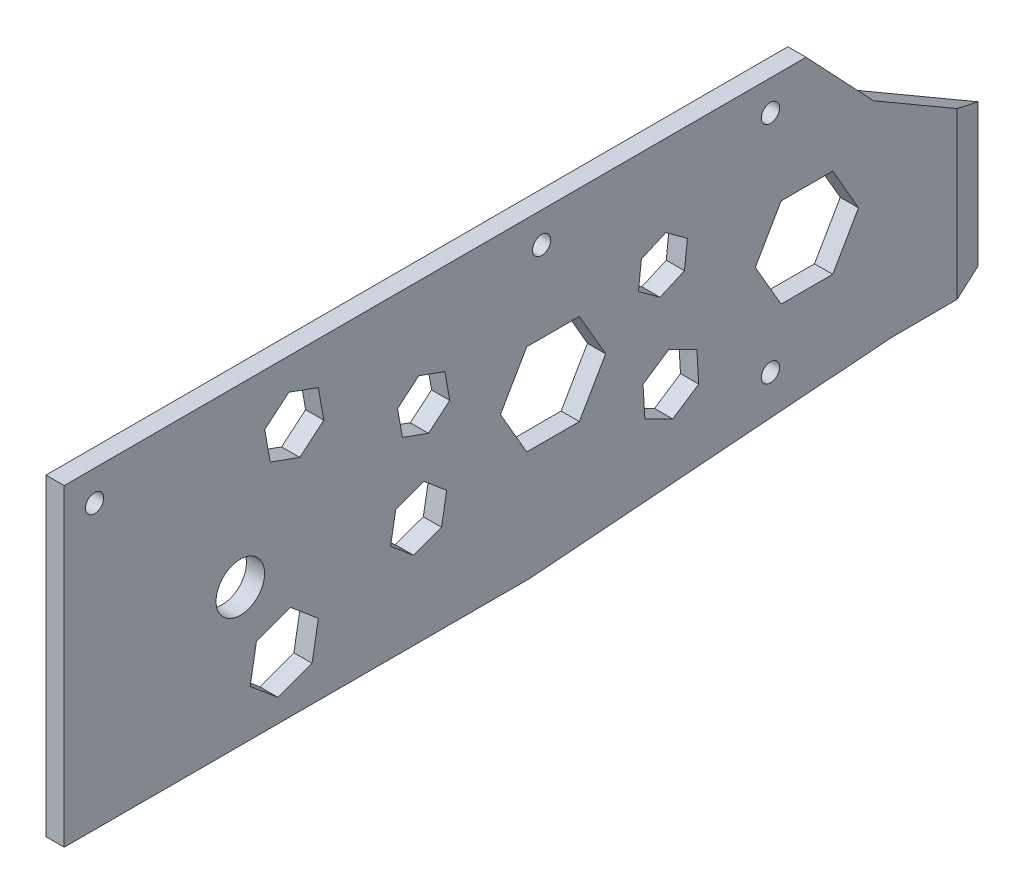
from build123d import *

# Parameters (mm, degrees)
CROQUIS1_W              = 161
CROQUIS1_H              = 51.5812
SALIENTE_EXTRUIR1_DEPTH = 3
CORTAR_EXTRUIR1_REACH   = 5
CROQUIS2_R              = 1.5
CROQUIS2_R_2            = 4
CORTAR_EXTRUIR2_REACH   = 5
CROQUIS3_R              = 1.5
CORTAR_EXTRUIR3_REACH   = 53.581
CORTAR_EXTRUIR4_REACH   = 5
CORTAR_EXTRUIR5_REACH   = 5
CORTAR_EXTRUIR6_REACH   = 5
CORTAR_EXTRUIR7_REACH   = 5
CORTAR_EXTRUIR8_REACH   = 5
CROQUIS9_R              = 1.5


with BuildPart() as part:
    # Croquis1 → Saliente-Extruir1 (new body)
    with BuildSketch(Plane(origin=(0, 0, 0), x_dir=(0, 0, -1), z_dir=(1, 0, 0))):
        Rectangle(CROQUIS1_W, CROQUIS1_H)
    extrude(amount=SALIENTE_EXTRUIR1_DEPTH)

    # Croquis2 → Cortar-Extruir1 (cut, up to next)
    with BuildSketch(Plane(origin=(3, 0, 0), x_dir=(0, 0, -1), z_dir=(1, 0, 0)), mode=Mode.PRIVATE) as cortar_extruir1_sk1:
        with Locations((-75.5, 20.7906)):
            Circle(CROQUIS2_R)
    cortar_extruir1_tool1 = extrude(cortar_extruir1_sk1.sketch, amount=-CORTAR_EXTRUIR1_REACH, mode=Mode.PRIVATE) & part.part
    add(cortar_extruir1_tool1.solids().sort_by_distance((3, 20.7906, 75.5))[0], mode=Mode.SUBTRACT)
    # Croquis2 → Cortar-Extruir1 (cut, up to next)
    with BuildSketch(Plane(origin=(3, 0, 0), x_dir=(0, 0, -1), z_dir=(1, 0, 0)), mode=Mode.PRIVATE) as cortar_extruir1_sk2:
        with Locations((-1.88, 20.7906)):
            Circle(CROQUIS2_R)
    cortar_extruir1_tool2 = extrude(cortar_extruir1_sk2.sketch, amount=-CORTAR_EXTRUIR1_REACH, mode=Mode.PRIVATE) & part.part
    add(cortar_extruir1_tool2.solids().sort_by_distance((3, 20.7906, 1.88))[0], mode=Mode.SUBTRACT)
    # Croquis2 → Cortar-Extruir1 (cut, up to next)
    with BuildSketch(Plane(origin=(3, 0, 0), x_dir=(0, 0, -1), z_dir=(1, 0, 0)), mode=Mode.PRIVATE) as cortar_extruir1_sk3:
        with Locations((-51.5, -3.2094)):
            Circle(CROQUIS2_R_2)
    cortar_extruir1_tool3 = extrude(cortar_extruir1_sk3.sketch, amount=-CORTAR_EXTRUIR1_REACH, mode=Mode.PRIVATE) & part.part
    add(cortar_extruir1_tool3.solids().sort_by_distance((3, -3.2094, 51.5))[0], mode=Mode.SUBTRACT)

    # Croquis3 → Cortar-Extruir2 (cut, up to next)
    with BuildSketch(Plane.ZY, mode=Mode.PRIVATE) as cortar_extruir2_sk1:
        with Locations((-35.801477372, -16.2094)):
            Circle(CROQUIS3_R)
    cortar_extruir2_tool1 = extrude(cortar_extruir2_sk1.sketch, amount=-CORTAR_EXTRUIR2_REACH, mode=Mode.PRIVATE) & part.part
    add(cortar_extruir2_tool1.solids().sort_by_distance((0, -16.2094, -35.801477))[0], mode=Mode.SUBTRACT)

    # Croquis4 → Cortar-Extruir3 (cut, up to next)
    with BuildSketch(Plane(origin=(0, 25.7906, 0), x_dir=(1, 0, 0), z_dir=(0, 1, 0)), mode=Mode.PRIVATE) as cortar_extruir3_sk1:
        Polygon((3, 80.5), (0, 80.5), (0, 72.980420108), (3, 66.546899347), align=None)
    cortar_extruir3_tool1 = extrude(cortar_extruir3_sk1.sketch, amount=-CORTAR_EXTRUIR3_REACH, mode=Mode.PRIVATE) & part.part
    add(cortar_extruir3_tool1.solids().sort_by_distance((1.649807, 25.7906, -74.971199))[0], mode=Mode.SUBTRACT)

    # Croquis5 → Cortar-Extruir4 (cut, up to next)
    with BuildSketch(Plane.ZY, mode=Mode.PRIVATE) as cortar_extruir4_sk1:
        Polygon((-72.980420108, -25.7906), (-72.980420108, -21.149469815), (-55.595458212, -21.2094), (3.759789946, -25.7906), align=None)
    cortar_extruir4_tool1 = extrude(cortar_extruir4_sk1.sketch, amount=-CORTAR_EXTRUIR4_REACH, mode=Mode.PRIVATE) & part.part
    add(cortar_extruir4_tool1.solids().sort_by_distance((0, -23.974753, -46.380283))[0], mode=Mode.SUBTRACT)

    # Croquis6 → Cortar-Extruir5 (cut, up to next)
    with BuildSketch(Plane.ZY, mode=Mode.PRIVATE) as cortar_extruir5_sk1:
        Polygon((-72.980420108, 25.7906), (-72.980420108, 2.2906), (-52.770420108, 14.0406), (-52.770420108, 25.7906), align=None)
    cortar_extruir5_tool1 = extrude(cortar_extruir5_sk1.sketch, amount=-CORTAR_EXTRUIR5_REACH, mode=Mode.PRIVATE) & part.part
    add(cortar_extruir5_tool1.solids().sort_by_distance((0, 16.651711, -63.998198))[0], mode=Mode.SUBTRACT)

    # Croquis7 → Cortar-Extruir6 (cut, up to next)
    with BuildSketch(Plane.ZY, mode=Mode.PRIVATE) as cortar_extruir6_sk1:
        Polygon((-52.770420108, 25.7906), (-41.670420108, 25.7906), (-52.770420108, 14.0406), align=None)
    cortar_extruir6_tool1 = extrude(cortar_extruir6_sk1.sketch, amount=-CORTAR_EXTRUIR6_REACH, mode=Mode.PRIVATE) & part.part
    add(cortar_extruir6_tool1.solids().sort_by_distance((0, 21.873933, -49.07042))[0], mode=Mode.SUBTRACT)

    # Croquis8 → Cortar-Extruir7 (cut, up to next)
    with BuildSketch(Plane.ZY, mode=Mode.PRIVATE) as cortar_extruir7_sk1:
        Polygon((8.660254038, 0), (4.330127019, 7.5), (-4.330127019, 7.5), (-8.660254038, 0), (-4.330127019, -7.5), (4.330127019, -7.5), align=None)
    cortar_extruir7_tool1 = extrude(cortar_extruir7_sk1.sketch, amount=-CORTAR_EXTRUIR7_REACH, mode=Mode.PRIVATE) & part.part
    add(cortar_extruir7_tool1.solids().sort_by_distance((0, 0, 0))[0], mode=Mode.SUBTRACT)
    # Croquis8 → Cortar-Extruir7 (cut, up to next)
    with BuildSketch(Plane.ZY, mode=Mode.PRIVATE) as cortar_extruir7_sk2:
        Polygon((25.604154883, 9.319150251), (22.099721379, 12.259719112), (17.800897292, 10.695075102), (17.006506709, 6.189862231), (20.510940213, 3.24929337), (24.8097643, 4.81393738), align=None)
    cortar_extruir7_tool2 = extrude(cortar_extruir7_sk2.sketch, amount=-CORTAR_EXTRUIR7_REACH, mode=Mode.PRIVATE) & part.part
    add(cortar_extruir7_tool2.solids().sort_by_distance((0, 7.754506, 21.305331))[0], mode=Mode.SUBTRACT)
    # Croquis8 → Cortar-Extruir7 (cut, up to next)
    with BuildSketch(Plane.ZY, mode=Mode.PRIVATE) as cortar_extruir7_sk3:
        Polygon((-23.988727728, -11.985830273), (-19.711232592, -14.811812276), (-15.125112818, -12.520383825), (-14.816488181, -7.402973371), (-19.093983317, -4.576991368), (-23.68010309, -6.868419819), align=None)
    cortar_extruir7_tool3 = extrude(cortar_extruir7_sk3.sketch, amount=-CORTAR_EXTRUIR7_REACH, mode=Mode.PRIVATE) & part.part
    add(cortar_extruir7_tool3.solids().sort_by_distance((0, -9.694402, -19.402608))[0], mode=Mode.SUBTRACT)
    # Croquis8 → Cortar-Extruir7 (cut, up to next)
    with BuildSketch(Plane.ZY, mode=Mode.PRIVATE) as cortar_extruir7_sk4:
        Polygon((-22.123245507, 9.737186974), (-21.644369238, 5.360424201), (-17.614543355, 3.58676183), (-14.063593742, 6.189862231), (-14.542470011, 10.566625004), (-18.572295894, 12.340287376), align=None)
    cortar_extruir7_tool4 = extrude(cortar_extruir7_sk4.sketch, amount=-CORTAR_EXTRUIR7_REACH, mode=Mode.PRIVATE) & part.part
    add(cortar_extruir7_tool4.solids().sort_by_distance((0, 7.963525, -18.09342))[0], mode=Mode.SUBTRACT)
    # Croquis8 → Cortar-Extruir7 (cut, up to next)
    with BuildSketch(Plane.ZY, mode=Mode.PRIVATE) as cortar_extruir7_sk5:
        Polygon((26.752701341, -9.737186974), (25.898994771, -4.895576423), (21.279183753, -3.214102725), (17.513079305, -6.374239578), (18.366785876, -11.215850129), (22.986596894, -12.897323827), align=None)
    cortar_extruir7_tool5 = extrude(cortar_extruir7_sk5.sketch, amount=-CORTAR_EXTRUIR7_REACH, mode=Mode.PRIVATE) & part.part
    add(cortar_extruir7_tool5.solids().sort_by_distance((0, -8.055713, 22.13289))[0], mode=Mode.SUBTRACT)
    # Croquis8 → Cortar-Extruir7 (cut, up to next)
    with BuildSketch(Plane.ZY, mode=Mode.PRIVATE) as cortar_extruir7_sk6:
        Polygon((-50.300771297, 0), (-46.052967767, -7.357411534), (-37.557360708, -7.357411534), (-33.309557178, 0), (-37.557360708, 7.357411534), (-46.052967767, 7.357411534), align=None)
    cortar_extruir7_tool6 = extrude(cortar_extruir7_sk6.sketch, amount=-CORTAR_EXTRUIR7_REACH, mode=Mode.PRIVATE) & part.part
    add(cortar_extruir7_tool6.solids().sort_by_distance((0, 0, -41.805164))[0], mode=Mode.SUBTRACT)
    # Croquis8 → Cortar-Extruir7 (cut, up to next)
    with BuildSketch(Plane.ZY, mode=Mode.PRIVATE) as cortar_extruir7_sk7:
        Polygon((37.746685044, 13.738669798), (41.711835056, 10.411513886), (46.575811604, 12.18185657), (47.474638141, 17.279355166), (43.509488129, 20.606511078), (38.645511581, 18.836168394), align=None)
    cortar_extruir7_tool7 = extrude(cortar_extruir7_sk7.sketch, amount=-CORTAR_EXTRUIR7_REACH, mode=Mode.PRIVATE) & part.part
    add(cortar_extruir7_tool7.solids().sort_by_distance((0, 15.509012, 42.610662))[0], mode=Mode.SUBTRACT)
    # Croquis8 → Cortar-Extruir7 (cut, up to next)
    with BuildSketch(Plane.ZY, mode=Mode.PRIVATE) as cortar_extruir7_sk8:
        Polygon((38.645511581, -14.065815903), (39.684095326, -19.955917015), (45.304364392, -22.001527663), (49.886049713, -18.157037201), (48.847465968, -12.266936089), (43.227196902, -10.221325441), align=None)
    cortar_extruir7_tool8 = extrude(cortar_extruir7_sk8.sketch, amount=-CORTAR_EXTRUIR7_REACH, mode=Mode.PRIVATE) & part.part
    add(cortar_extruir7_tool8.solids().sort_by_distance((0, -16.111427, 44.265781))[0], mode=Mode.SUBTRACT)

    # Croquis9 → Cortar-Extruir8 (cut, up to next)
    with BuildSketch(Plane.ZY, mode=Mode.PRIVATE) as cortar_extruir8_sk1:
        with Locations((-35.801477372, 20.7906)):
            Circle(CROQUIS9_R)
    cortar_extruir8_tool1 = extrude(cortar_extruir8_sk1.sketch, amount=-CORTAR_EXTRUIR8_REACH, mode=Mode.PRIVATE) & part.part
    add(cortar_extruir8_tool1.solids().sort_by_distance((0, 20.7906, -35.801477))[0], mode=Mode.SUBTRACT)


solid = part.part
